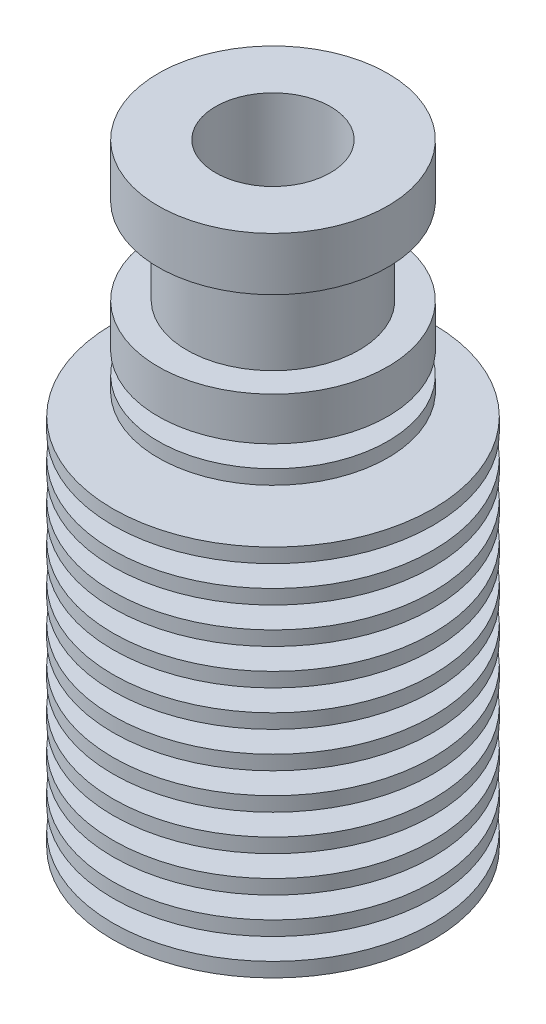
from build123d import *

# Parameters (mm, degrees)
HOLE_WIZARD_1_D     = 5.917
HOLE_WIZARD_1_DEPTH = 14.8
HOLE_WIZARD_1_TIP   = 1.777646141
CHAMFER_1_SIZE      = 0.5


with BuildPart() as part:
    # Эскиз1 → Повернуть1 (revolve)
    with BuildSketch(Plane(origin=(0, 0, 0), x_dir=(0, 0, -1), z_dir=(1, 0, 0))):
        Polygon((-4, 42.7), (-4, 34.7), (-2.1, 33.603034489), (-2.1, 0), (-11.15, 0), (-11.15, 1), (-6.099727925, 1), (-5.968494929, 2.5), (-11.15, 2.5), (-11.15, 3.5), (-5.881006266, 3.5), (-5.749773271, 5), (-11.15, 5), (-11.15, 6), (-5.662284607, 6), (-5.531051612, 7.5), (-11.15, 7.5), (-11.15, 8.5), (-5.443562948, 8.5), (-5.312329953, 10), (-11.15, 10), (-11.15, 11), (-5.224841289, 11), (-5.093608294, 12.5), (-11.15, 12.5), (-11.15, 13.5), (-5.006119631, 13.5), (-4.874886635, 15), (-11.15, 15), (-11.15, 16), (-4.787397972, 16), (-4.656164976, 17.5), (-11.15, 17.5), (-11.15, 18.5), (-4.568676313, 18.5), (-4.437443318, 20), (-11.15, 20), (-11.15, 21), (-4.349954654, 21), (-4.218721659, 22.5), (-11.15, 22.5), (-11.15, 23.5), (-4.131232995, 23.5), (-4, 25), (-11.15, 25), (-11.15, 26), (-4, 26), (-4, 27.5), (-8, 27.5), (-8, 28.5), (-4, 28.5), (-4, 30), (-8, 30), (-8, 33), (-6, 33), (-6, 39), (-8, 39), (-8, 42.7), align=None)
    revolve(axis=Axis((0, 0, 0), (0, 1, 0)))

    # Отверстие1
    with Locations(Plane.XZ):
        with Locations((0, 0)):
            Hole(HOLE_WIZARD_1_D / 2, depth=HOLE_WIZARD_1_DEPTH)
            with Locations((0, 0, -(HOLE_WIZARD_1_DEPTH + HOLE_WIZARD_1_TIP / 2))):  # 118° drill point
                Cone(0, HOLE_WIZARD_1_D / 2, HOLE_WIZARD_1_TIP, mode=Mode.SUBTRACT)

    # Фаска1
    chamfer_1_edges = [part.edges().sort_by_distance(p)[0] for p in [
        (2.9585, 0, 0),
    ]]
    chamfer(chamfer_1_edges, length=CHAMFER_1_SIZE)


solid = part.part
